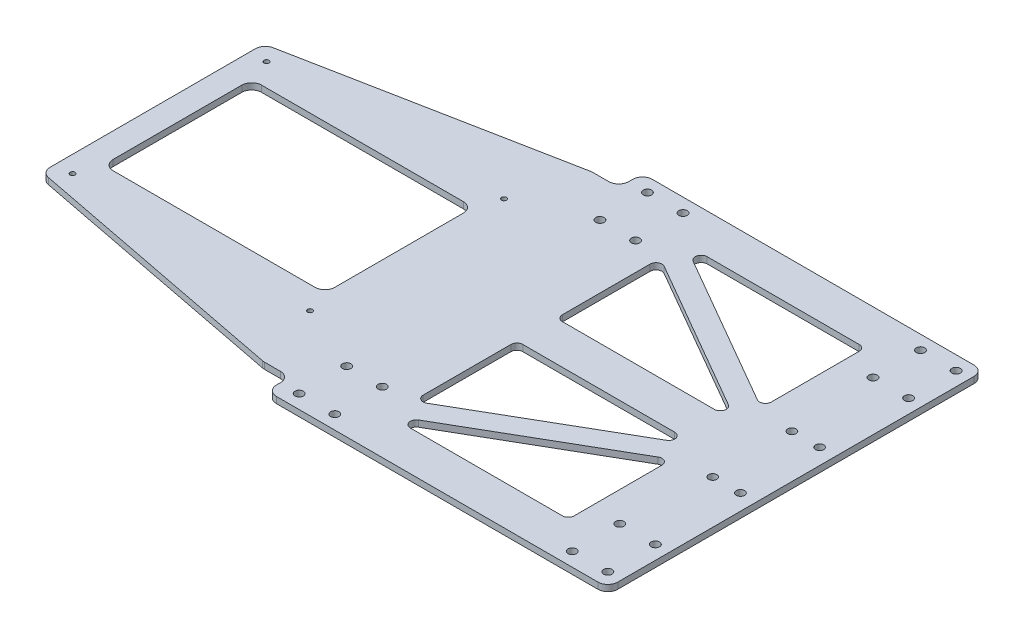
from build123d import *

# Parameters (mm, degrees)
SKETCH1_W                           = 325
SKETCH1_H                           = 190
PLATFORM_DEPTH                      = 3.175
SKETCH2_W                           = 112
SKETCH2_H                           = 75
MICROPLATE_CUTOUT_DEPTH             = 4.175
SKETCH3_R                           = 1
LEAD_NUT_HOLE_POSITIONS_DEPTH       = 4.175
SKETCH4_R                           = 2.125
LINEAR_BEARING_MOUNTING_HOLES_DEPTH = 4.175
LPATTERN1_COUNT                     = 2
LPATTERN1_PITCH                     = 138
SKETCH10_W                          = 152.5
SKETCH10_H                          = 12
CUT_EXTRUDE1_DEPTH                  = 4.175
CHAMFER1_SIZE                       = 27
CHAMFER1_SIZE2                      = 138.902958431
FILLET1_R                           = 5
M3X0_5_TAPPED_HOLE1_D               = 2.5
M5X0_8_TAPPED_HOLE1_D               = 4.2
CUT_EXTRUDE3_DEPTH                  = 4.175
FILLET3_R                           = 3


with BuildPart() as part:
    # Sketch1 → Platform (new body)
    with BuildSketch(Plane(origin=(0, 0, 0), x_dir=(1, 0, 0), z_dir=(0, 1, 0))):
        Rectangle(SKETCH1_W, SKETCH1_H)
    extrude(amount=PLATFORM_DEPTH)

    # Sketch2 → Microplate Cutout (cut, through all)
    with BuildSketch(Plane(origin=(0, 3.175, 0), x_dir=(1, 0, 0), z_dir=(0, 1, 0))):
        with Locations((-94, 0)):
            Rectangle(SKETCH2_W, SKETCH2_H)
    extrude(amount=-MICROPLATE_CUTOUT_DEPTH, mode=Mode.SUBTRACT)

    # Sketch3 → Lead Nut Hole Positions (cut, through all)
    with BuildSketch(Plane(origin=(0, 3.175, 0), x_dir=(1, 0, 0), z_dir=(0, 1, 0))):
        with Locations((140.5, 20)):
            Circle(SKETCH3_R)
        with Locations((154.5, 20)):
            Circle(SKETCH3_R)
        with Locations((154.5, -20)):
            Circle(SKETCH3_R)
        with Locations((140.5, -20)):
            Circle(SKETCH3_R)
    extrude(amount=-LEAD_NUT_HOLE_POSITIONS_DEPTH, mode=Mode.SUBTRACT)

    # Sketch4 → Linear Bearing Mounting Holes (cut, through all)
    with BuildSketch(Plane(origin=(0, 3.175, 0), x_dir=(1, 0, 0), z_dir=(0, 1, 0))):
        with Locations((17.5, 88)):
            Circle(SKETCH4_R)
        with Locations((17.5, 64)):
            Circle(SKETCH4_R)
        with Locations((-0.5, 88)):
            Circle(SKETCH4_R)
        with Locations((-0.5, 64)):
            Circle(SKETCH4_R)
        with Locations((-0.5, -64)):
            Circle(SKETCH4_R)
        with Locations((-0.5, -88)):
            Circle(SKETCH4_R)
        with Locations((17.5, -64)):
            Circle(SKETCH4_R)
        with Locations((17.5, -88)):
            Circle(SKETCH4_R)
    linear_bearing_mounting_holes = extrude(amount=-LINEAR_BEARING_MOUNTING_HOLES_DEPTH, mode=Mode.SUBTRACT)

    # LPattern1: Linear Bearing Mounting Holes ×2
    with Locations(*[(i * LPATTERN1_PITCH, 0, 0) for i in range(1, LPATTERN1_COUNT)]):
        add(linear_bearing_mounting_holes, mode=Mode.SUBTRACT)

    # Sketch10 → Cut-Extrude1 (cut, through all)
    with BuildSketch(Plane(origin=(0, 3.175, 0), x_dir=(1, 0, 0), z_dir=(0, 1, 0))):
        with Locations((-86.25, 89)):
            Rectangle(SKETCH10_W, SKETCH10_H)
        with Locations((-86.25, -89)):
            Rectangle(SKETCH10_W, SKETCH10_H)
    extrude(amount=-CUT_EXTRUDE1_DEPTH, mode=Mode.SUBTRACT)

    # Chamfer1
    chamfer1_edges = [part.edges().sort_by_distance(p)[0] for p in [
        (-162.5, 1.5875, -83),
        (-162.5, 1.5875, 83),
    ]]
    chamfer1_side = [part.faces().sort_by_distance(p)[0] for p in [
        (-162.5, 1.5875, 0),
    ]]
    chamfer(chamfer1_edges, length=CHAMFER1_SIZE, length2=CHAMFER1_SIZE2, reference=chamfer1_side[0])

    # Fillet1
    fillet1_edges = [part.edges().sort_by_distance(p)[0] for p in [
        (-10, 1.5875, -95),
        (-10, 1.5875, -83),
        (-10, 1.5875, 83),
        (-10, 1.5875, 95),
        (-23.597041569, 1.5875, -83),
        (-162.5, 1.5875, 56),
        (-162.5, 1.5875, -56),
        (-23.597041569, 1.5875, 83),
        (-38, 1.5875, -37.5),
        (-38, 1.5875, 37.5),
        (-150, 1.5875, 37.5),
        (-150, 1.5875, -37.5),
        (162.5, 1.5875, 95),
        (162.5, 1.5875, -95),
    ]]
    fillet(fillet1_edges, radius=FILLET1_R)

    # M3x0.5 Tapped Hole1 (through all)
    with Locations(Plane(origin=(0, 3.175, 0), x_dir=(1, 0, 0), z_dir=(0, 1, 0))):
        with Locations((-94, 0), (-34, 49), (-154, -49), (-154, 49), (-34, -49)):
            Hole(M3X0_5_TAPPED_HOLE1_D / 2)

    # M5x0.8 Tapped Hole1 (through all)
    with Locations(Plane(origin=(0, 3.175, 0), x_dir=(1, 0, 0), z_dir=(0, 1, 0))):
        with Locations((154.5, 20), (140.5, 20), (154.5, -20), (140.5, -20)):
            Hole(M5X0_8_TAPPED_HOLE1_D / 2)

    # Sketch12 → Cut-Extrude3 (cut, through all)
    with BuildSketch(Plane(origin=(0, 3.175, 0), x_dir=(1, 0, 0), z_dir=(0, 1, 0))):
        Polygon((122.5, 22.461125504), (31.5, 75), (122.5, 75), align=None)
        Polygon((122.5, 10), (31.5, 62.538874496), (31.5, 10), align=None)
        Polygon((31.5, -10), (122.5, -10), (31.5, -62.538874496), align=None)
        Polygon((31.5, -75), (122.5, -75), (122.5, -22.461125504), align=None)
    extrude(amount=-CUT_EXTRUDE3_DEPTH, mode=Mode.SUBTRACT)

    # Fillet3
    fillet3_edges = [part.edges().sort_by_distance(p)[0] for p in [
        (122.5, 1.5875, -10),
        (31.5, 1.5875, -10),
        (31.5, 1.5875, -62.538874496),
        (122.5, 1.5875, 22.461125504),
        (122.5, 1.5875, 75),
        (31.5, 1.5875, 75),
        (31.5, 1.5875, 62.538874496),
        (31.5, 1.5875, 10),
        (122.5, 1.5875, 10),
        (122.5, 1.5875, -75),
        (122.5, 1.5875, -22.461125504),
        (31.5, 1.5875, -75),
    ]]
    fillet(fillet3_edges, radius=FILLET3_R)


solid = part.part
